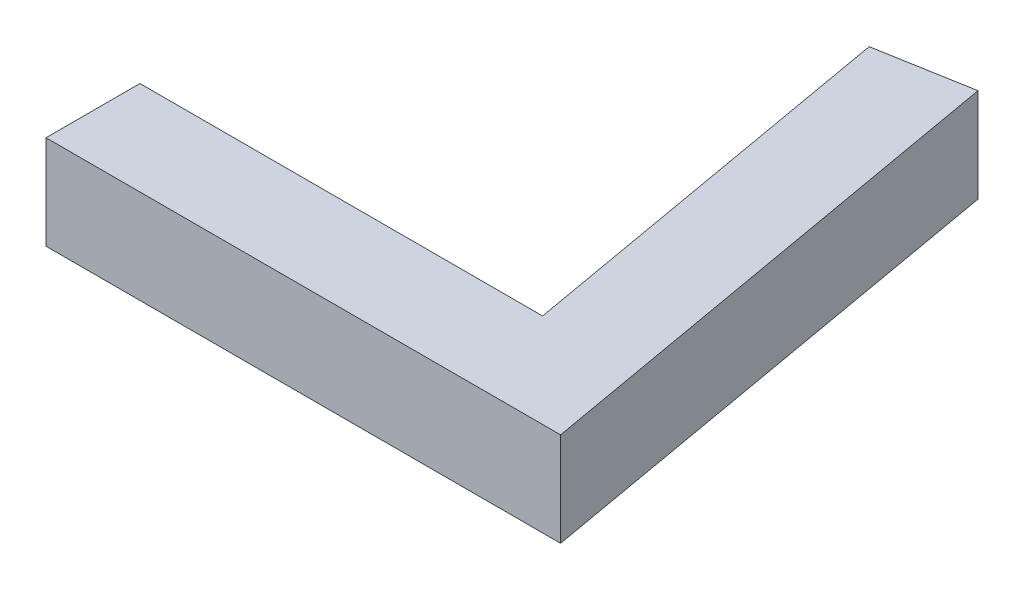
from build123d import *

# Parameters (mm, degrees)
BOSS_EXTRUDE1_DEPTH = 3.5
SKETCH3_R           = 0.675
CUT_EXTRUDE1_DEPTH  = 10
SKETCH4_R           = 0.675
CUT_EXTRUDE3_DEPTH  = 10


with BuildPart() as part:
    # Sketch2 → Boss-Extrude1 (new body)
    with BuildSketch(Plane(origin=(0, 0, 0), x_dir=(1, 0, 0), z_dir=(0, 1, 0))):
        Polygon((-2.604722665, 14.772116295), (0, 0), (-15, 0), (-15, -3.5), (4.171137574, -3.5), (0.842104471, 15.379884917), align=None)
    extrude(amount=BOSS_EXTRUDE1_DEPTH)

    # Sketch3 → Cut-Extrude1 (cut)
    with BuildSketch(Plane.ZY.offset(15)):
        with Locations((1.75, 1.75)):
            Circle(SKETCH3_R)
    extrude(amount=-CUT_EXTRUDE1_DEPTH, mode=Mode.SUBTRACT)

    # Sketch4 → Cut-Extrude3 (cut)
    with BuildSketch(Plane(origin=(-2.604722665, 0, -14.772116295), x_dir=(-0.9848077530122086, 0, 0.17364817766692825), z_dir=(-0.17364817766692825, 0, -0.9848077530122086))):
        with Locations((-1.75, 1.75)):
            Circle(SKETCH4_R)
    extrude(amount=-CUT_EXTRUDE3_DEPTH, mode=Mode.SUBTRACT)


solid = part.part
